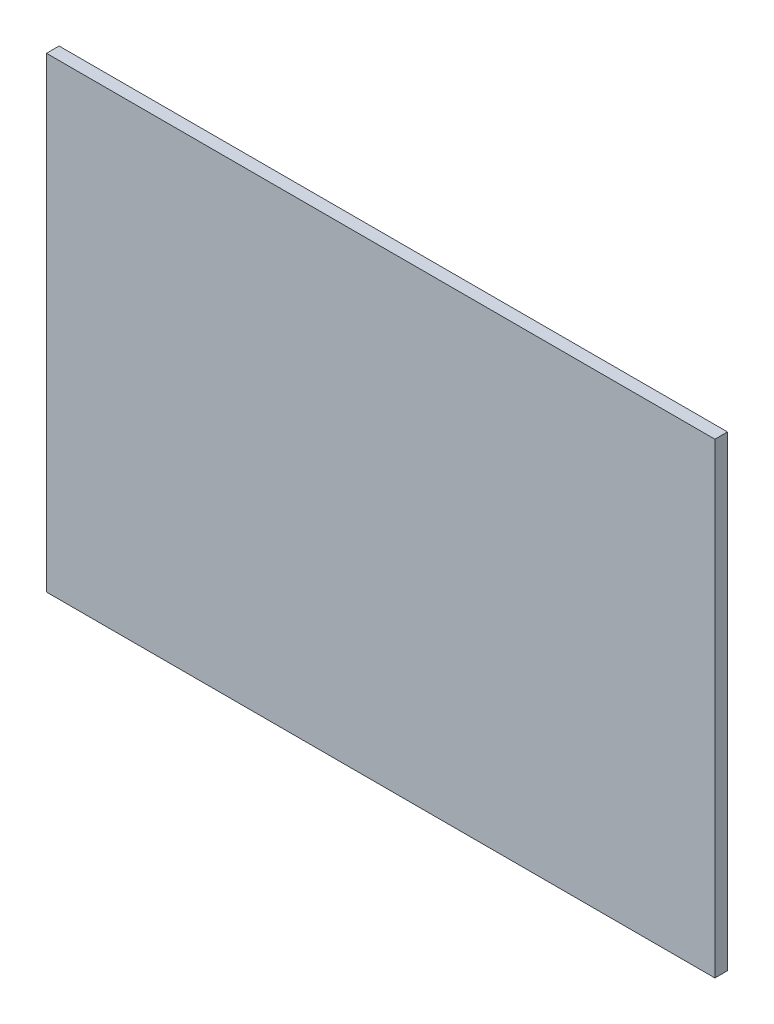
from build123d import *

# Parameters (mm, degrees)
SKETCH1_W           = 530
SKETCH1_H           = 370
BOSS_EXTRUDE1_DEPTH = 10


with BuildPart() as part:
    # Sketch1 → Boss-Extrude1 (new body)
    with BuildSketch(Plane.XY):
        Rectangle(SKETCH1_W, SKETCH1_H)
    extrude(amount=BOSS_EXTRUDE1_DEPTH)


solid = part.part
